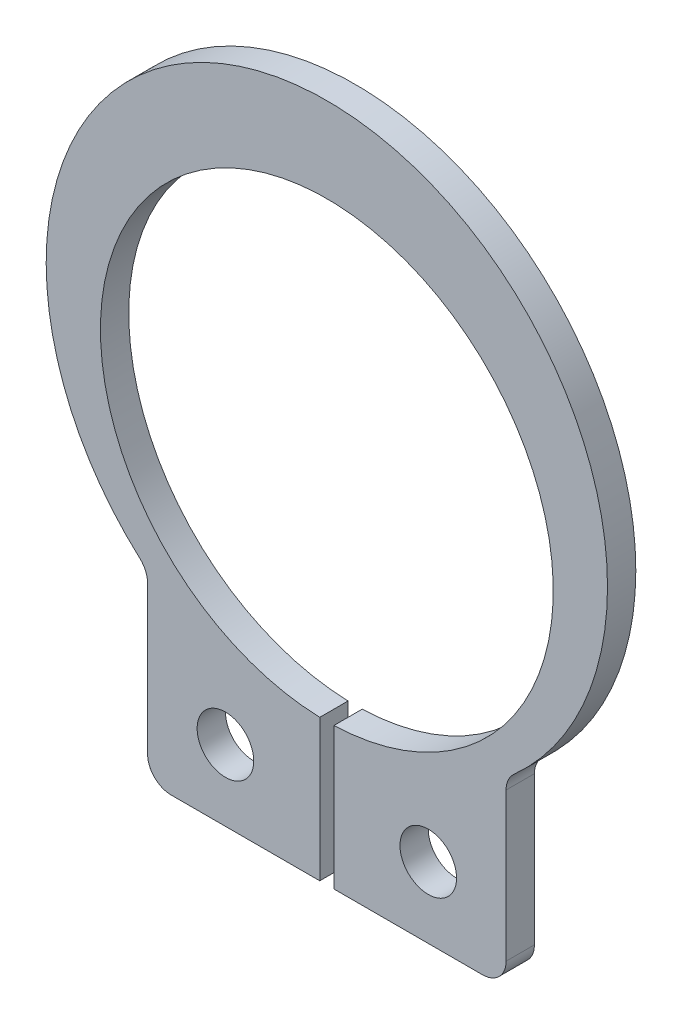
from build123d import *

# Parameters (mm, degrees)
BOSS_EXTRUDE1_DEPTH = 0.6
SKETCH2_R           = 0.6
CUT_EXTRUDE1_DEPTH  = 1.6


with BuildPart() as part:
    # Sketch1 → Boss-Extrude1 (new body)
    with BuildSketch(Plane.XY):
        with BuildLine():
            Line((-3.8, -4.157546152), (-3.8, -7.3))
            ThreePointArc((-3.8, -7.3), (-3.653553391, -7.653553391), (-3.3, -7.8))
            Line((-3.3, -7.8), (-0.15, -7.8))
            Line((-0.15, -7.8), (-0.15, -4.797655678))
            ThreePointArc((-0.15, -4.797655678), (0, 4.8), (0.15, -4.797655678))
            Line((0.15, -4.797655678), (0.15, -7.8))
            Line((0.15, -7.8), (3.3, -7.8))
            ThreePointArc((3.3, -7.8), (3.653553391, -7.653553391), (3.8, -7.3))
            Line((3.8, -7.3), (3.8, -4.157546152))
            ThreePointArc((3.8, -4.157546152), (3.843564535, -3.953422006), (3.966666667, -3.784868155))
            ThreePointArc((3.966666667, -3.784868155), (0, 6.6), (-3.966666667, -3.784868155))
            ThreePointArc((-3.966666667, -3.784868155), (-3.843564535, -3.953422006), (-3.8, -4.157546152))
        make_face()
    extrude(amount=-BOSS_EXTRUDE1_DEPTH)

    # Sketch2 → Cut-Extrude1 (cut, through all)
    with BuildSketch(Plane.XY):
        with Locations((-2.15, -6.3)):
            Circle(SKETCH2_R)
        with Locations((2.15, -6.3)):
            Circle(SKETCH2_R)
    extrude(amount=-CUT_EXTRUDE1_DEPTH, mode=Mode.SUBTRACT)


solid = part.part
